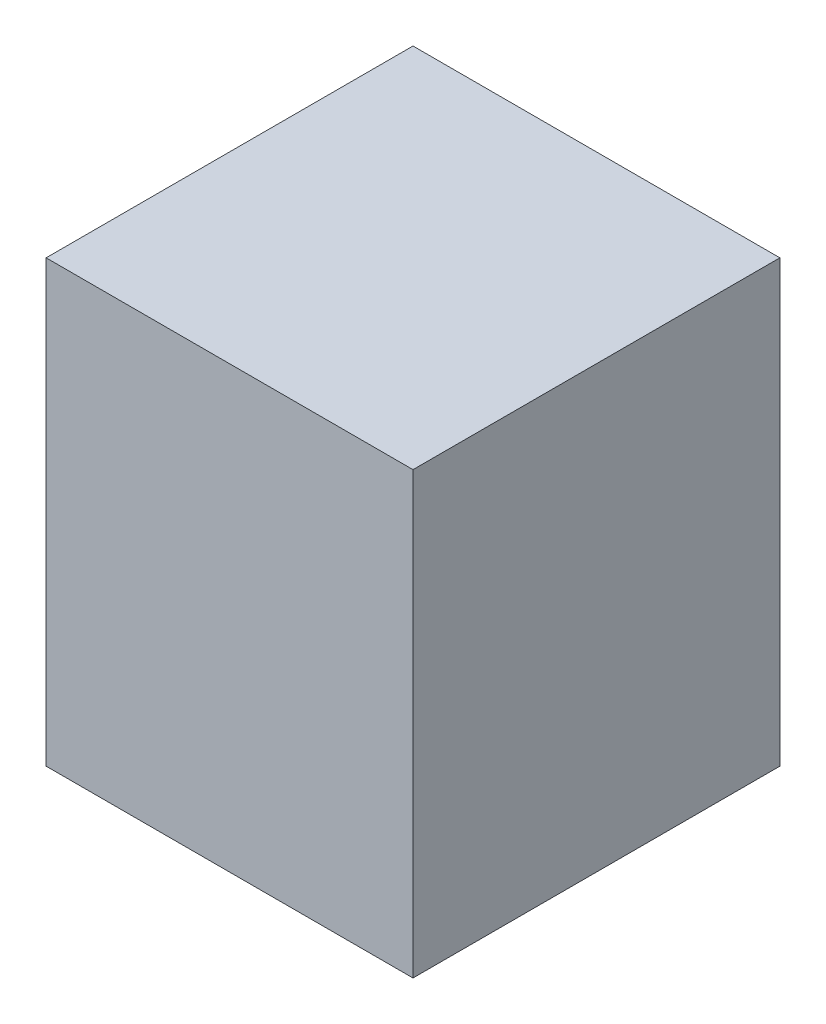
from build123d import *

# Parameters (mm, degrees)
SKETCH1_W           = 50
SKETCH1_H           = 50
BOSS_EXTRUDE1_DEPTH = 30


with BuildPart() as part:
    # Sketch1 → Boss-Extrude1 (new body, symmetric)
    with BuildSketch(Plane(origin=(0, 0, 0), x_dir=(1, 0, 0), z_dir=(0, 1, 0))):
        Rectangle(SKETCH1_W, SKETCH1_H)
    extrude(amount=BOSS_EXTRUDE1_DEPTH, both=True)


solid = part.part
